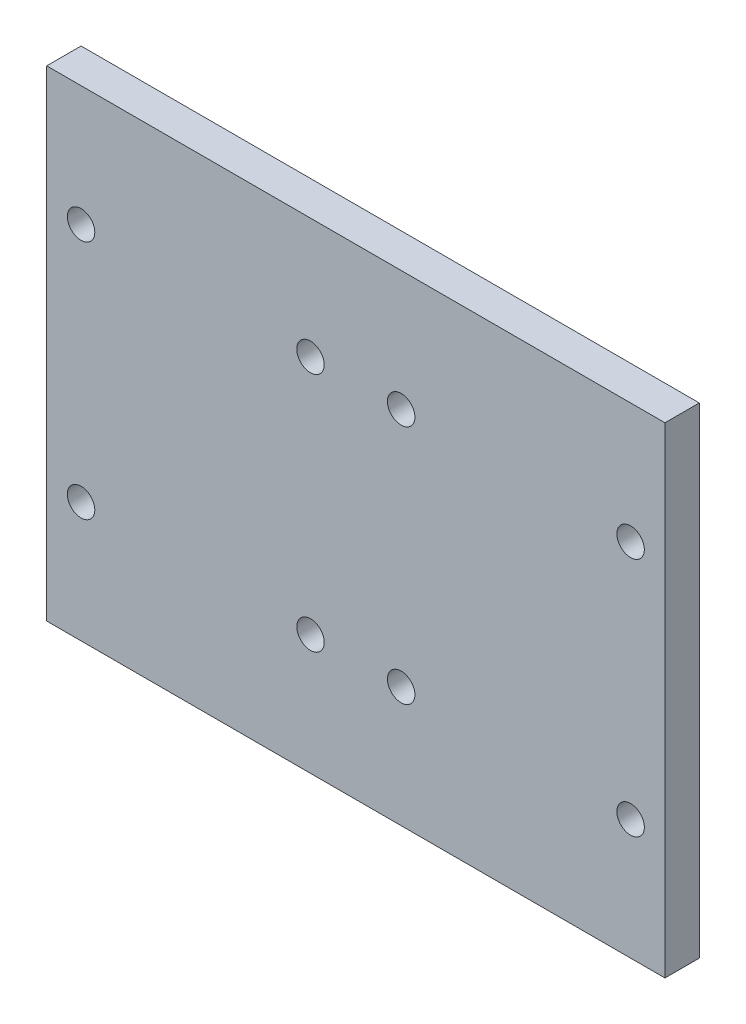
from build123d import *

# Parameters (mm, degrees)
SKETCH1_W           = 90
SKETCH1_H           = 70
SKETCH1_R           = 2
BOSS_EXTRUDE1_DEPTH = 5


with BuildPart() as part:
    # Sketch1 → Boss-Extrude1 (new body)
    with BuildSketch(Plane.XY):
        Rectangle(SKETCH1_W, SKETCH1_H)
        with Locations((-6.6, 17.5)):
            Circle(SKETCH1_R, mode=Mode.SUBTRACT)
        with Locations((6.6, 17.5)):
            Circle(SKETCH1_R, mode=Mode.SUBTRACT)
        with Locations((-6.6, -17.5)):
            Circle(SKETCH1_R, mode=Mode.SUBTRACT)
        with Locations((-40, 17.5)):
            Circle(SKETCH1_R, mode=Mode.SUBTRACT)
        with Locations((-40, -17.5)):
            Circle(SKETCH1_R, mode=Mode.SUBTRACT)
        with Locations((40, 17.5)):
            Circle(SKETCH1_R, mode=Mode.SUBTRACT)
        with Locations((6.6, -17.5)):
            Circle(SKETCH1_R, mode=Mode.SUBTRACT)
        with Locations((40, -17.5)):
            Circle(SKETCH1_R, mode=Mode.SUBTRACT)
    extrude(amount=BOSS_EXTRUDE1_DEPTH)


solid = part.part
